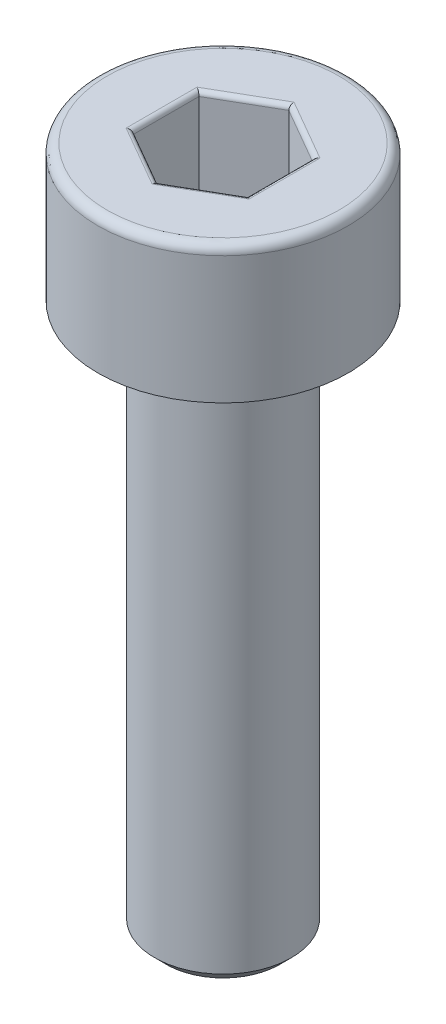
from build123d import *

# Parameters (mm, degrees)
CHAMFER1_SIZE      = 0.25
FILLET1_R          = 0.2
CUT_EXTRUDE1_DEPTH = 2
FILLET2_R          = 0.1


with BuildPart() as part:
    # Sketch1 → Revolve1 (revolve)
    with BuildSketch(Plane.XY):
        Polygon((0, -15), (-1.5, -15), (-1.5, -3), (-2.75, -3), (-2.75, 0), (0, 0), align=None)
    revolve(axis=Axis((0, 0, 0), (0, -1, 0)))

    # Chamfer1
    chamfer1_edges = [part.edges().sort_by_distance(p)[0] for p in [
        (1.5, -3, 0),
        (1.5, -15, 0),
    ]]
    chamfer(chamfer1_edges, length=CHAMFER1_SIZE)

    # Fillet1
    fillet1_edges = [part.edges().sort_by_distance(p)[0] for p in [
        (2.75, 0, 0),
    ]]
    fillet(fillet1_edges, radius=FILLET1_R)

    # Sketch2 → Cut-Extrude1 (cut)
    with BuildSketch(Plane(origin=(0, 0, 0), x_dir=(1, 0, 0), z_dir=(0, 1, 0))):
        Polygon((0, 1.443375673), (-1.25, 0.721687836), (-1.25, -0.721687836), (0, -1.443375673), (1.25, -0.721687836), (1.25, 0.721687836), align=None)
    extrude(amount=-CUT_EXTRUDE1_DEPTH, mode=Mode.SUBTRACT)

    # Fillet2
    fillet2_edges = [part.edges().sort_by_distance(p)[0] for p in [
        (0.625, -2, -1.082531755),
        (1.25, -2, 0),
        (0.625, -2, 1.082531755),
        (-0.625, -2, 1.082531755),
        (-1.25, -2, 0),
        (-0.625, -2, -1.082531755),
        (0.625, 0, -1.082531755),
        (-0.625, 0, -1.082531755),
        (-1.25, 0, 0),
        (-0.625, 0, 1.082531755),
        (0.625, 0, 1.082531755),
        (1.25, 0, 0),
    ]]
    fillet(fillet2_edges, radius=FILLET2_R)


solid = part.part
